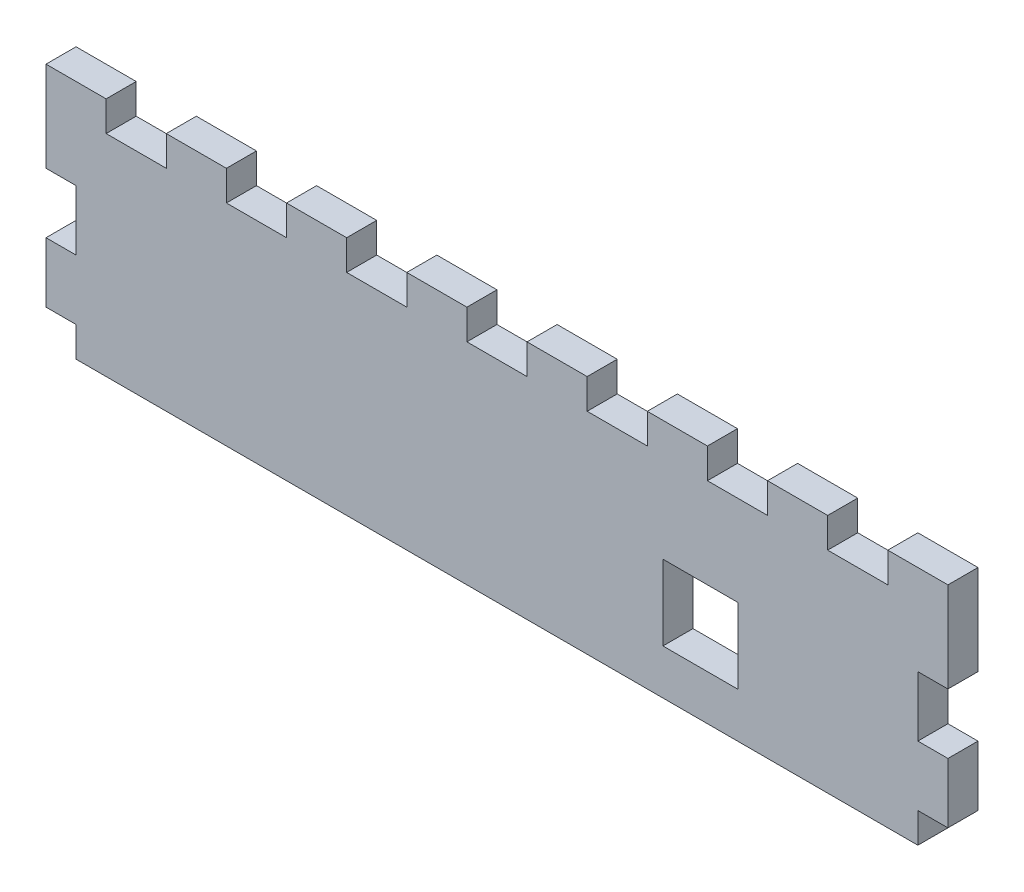
from build123d import *

# Parameters (mm, degrees)
SKETCH1_W           = 190.5
SKETCH1_H           = 50.8
BOSS_EXTRUDE1_DEPTH = 6.35
SKETCH2_W           = 6.35
SKETCH2_H           = 12.7
CUT_EXTRUDE1_DEPTH  = 7.35
SKETCH3_W           = 6.35
SKETCH3_H           = 6.35
CUT_EXTRUDE2_DEPTH  = 7.35
SKETCH4_W           = 12.7
SKETCH4_H           = 6.35
CUT_EXTRUDE3_DEPTH  = 7.35
LPATTERN1_COUNT     = 7
LPATTERN1_PITCH     = 25.4
SKETCH5_W           = 15.875
SKETCH5_H           = 15.875
CUT_EXTRUDE4_DEPTH  = 7.35


with BuildPart() as part:
    # Sketch1 → Boss-Extrude1 (new body)
    with BuildSketch(Plane.XY):
        Rectangle(SKETCH1_W, SKETCH1_H)
    extrude(amount=BOSS_EXTRUDE1_DEPTH)

    # Sketch2 → Cut-Extrude1 (cut, through all)
    with BuildSketch(Plane.XY.offset(6.35)):
        with Locations((-92.075, 0)):
            Rectangle(SKETCH2_W, SKETCH2_H)
    cut_extrude1 = extrude(amount=-CUT_EXTRUDE1_DEPTH, mode=Mode.SUBTRACT)

    # Sketch3 → Cut-Extrude2 (cut, through all)
    with BuildSketch(Plane.XY.offset(6.35)):
        with Locations((-92.075, -22.225)):
            Rectangle(SKETCH3_W, SKETCH3_H)
    cut_extrude2 = extrude(amount=-CUT_EXTRUDE2_DEPTH, mode=Mode.SUBTRACT)

    # Mirror1: Cut-Extrude2 across plane
    add(cut_extrude2.mirror(Plane(origin=(0, 0, 0), x_dir=(0, 0, 1), z_dir=(1, 0, 0))), mode=Mode.SUBTRACT)

    # Mirror2: Cut-Extrude1 across plane
    add(cut_extrude1.mirror(Plane(origin=(0, 0, 0), x_dir=(0, 0, 1), z_dir=(1, 0, 0))), mode=Mode.SUBTRACT)

    # Sketch4 → Cut-Extrude3 (cut, through all)
    with BuildSketch(Plane.XY.offset(6.35)):
        with Locations((-76.2, 22.225)):
            Rectangle(SKETCH4_W, SKETCH4_H)
    cut_extrude3 = extrude(amount=-CUT_EXTRUDE3_DEPTH, mode=Mode.SUBTRACT)

    # LPattern1: Cut-Extrude3 ×7
    with Locations(*[(i * LPATTERN1_PITCH, 0, 0) for i in range(1, LPATTERN1_COUNT)]):
        add(cut_extrude3, mode=Mode.SUBTRACT)

    # Sketch5 → Cut-Extrude4 (cut, through all)
    with BuildSketch(Plane.XY.offset(6.35)):
        with Locations((42.9895, -7.9375)):
            Rectangle(SKETCH5_W, SKETCH5_H)
    extrude(amount=-CUT_EXTRUDE4_DEPTH, mode=Mode.SUBTRACT)


solid = part.part
